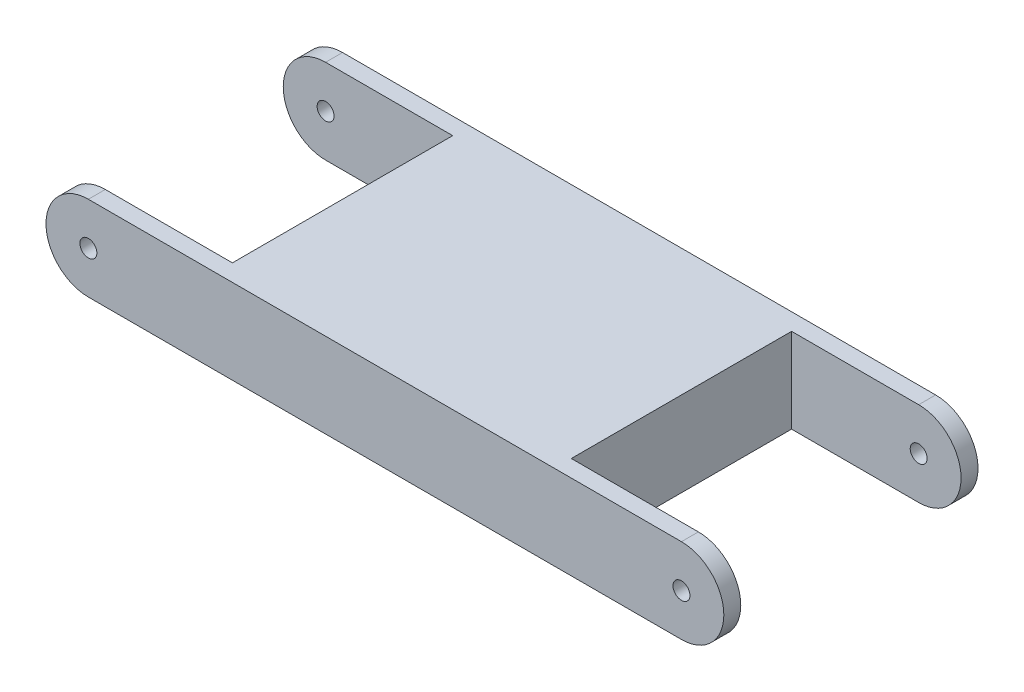
from build123d import *

# Parameters (mm, degrees)
EXTRUDE_1_DEPTH          = 30
SKETCH_2_R               = 1
CUT_EXTRUDE_4_DEPTH      = 31
CUT_EXTRUDE_4_DEPTH_BACK = 30
SKETCH_3_W               = 20
SKETCH_3_H               = 26
CUT_EXTRUDE_5_DEPTH      = 30
CUT_EXTRUDE_5_DEPTH_BACK = 30


with BuildPart() as part:
    # 草圖1 → 填料-伸長1 (new body)
    with BuildSketch(Plane.XY):
        with BuildLine():
            Line((-35, 5), (35, 5))
            ThreePointArc((35, 5), (40, 0), (35, -5))
            Line((35, -5), (-35, -5))
            ThreePointArc((-35, -5), (-40, 0), (-35, 5))
        make_face()
    extrude(amount=EXTRUDE_1_DEPTH)

    # 草圖2 → 除料-伸長4 (cut, two sides)
    with BuildSketch(Plane.XY) as cut_extrude_4_sk:
        with Locations((-35, 0)):
            Circle(SKETCH_2_R)
        with Locations((35, 0)):
            Circle(SKETCH_2_R)
    extrude(amount=CUT_EXTRUDE_4_DEPTH, mode=Mode.SUBTRACT)
    extrude(cut_extrude_4_sk.sketch, amount=-CUT_EXTRUDE_4_DEPTH_BACK, mode=Mode.SUBTRACT)

    # 草圖3 → 除料-伸長5 (cut, two sides)
    with BuildSketch(Plane(origin=(0, 0, 0), x_dir=(1, 0, 0), z_dir=(0, 1, 0))) as cut_extrude_5_sk:
        with Locations((-30, -15)):
            Rectangle(SKETCH_3_W, SKETCH_3_H)
        with Locations((30, -15)):
            Rectangle(SKETCH_3_W, SKETCH_3_H)
    extrude(amount=CUT_EXTRUDE_5_DEPTH, mode=Mode.SUBTRACT)
    extrude(cut_extrude_5_sk.sketch, amount=-CUT_EXTRUDE_5_DEPTH_BACK, mode=Mode.SUBTRACT)


solid = part.part
